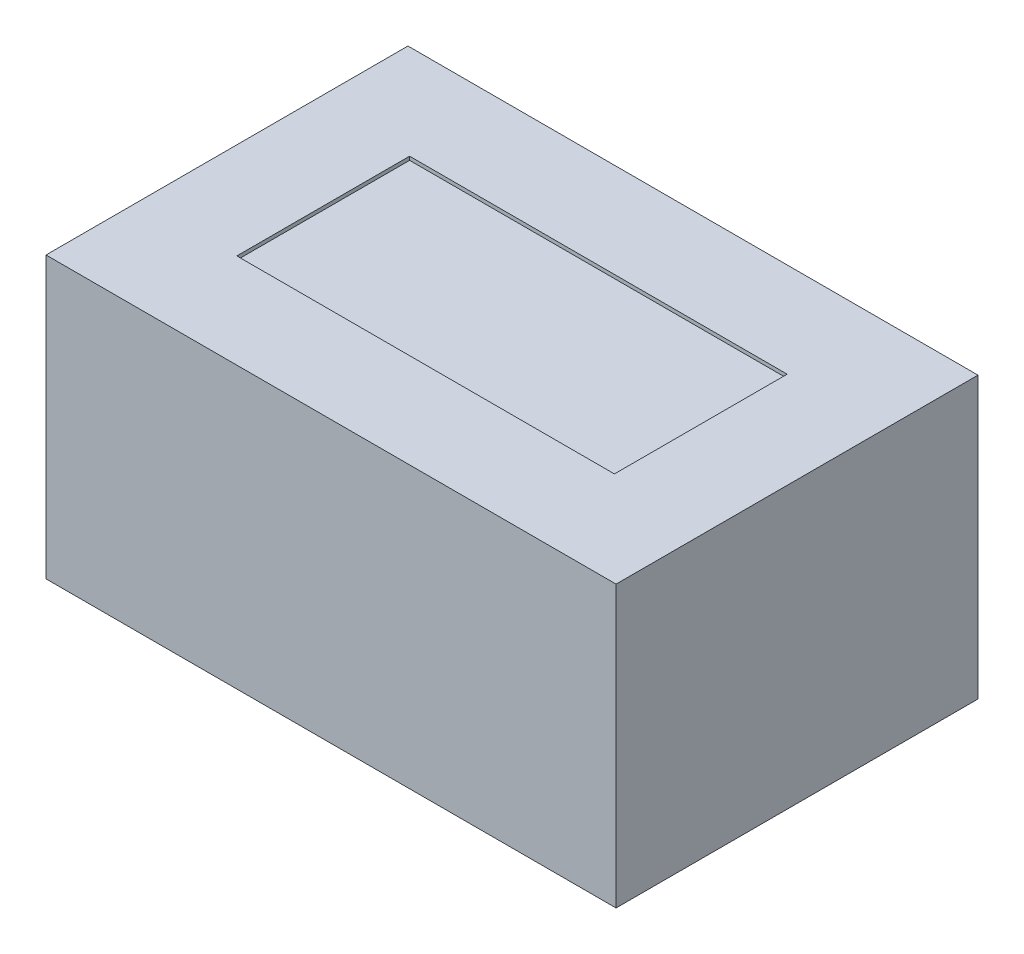
from build123d import *

# Parameters (mm, degrees)
CROQUIS1_W              = 315
CROQUIS1_H              = 200
SALIENTE_EXTRUIR1_DEPTH = 155
CROQUIS2_W              = 208.648711884
CROQUIS2_H              = 95.466627608
CORTAR_EXTRUIR1_DEPTH   = 2


with BuildPart() as part:
    # Croquis1 → Saliente-Extruir1 (new body)
    with BuildSketch(Plane(origin=(0, 0, 0), x_dir=(1, 0, 0), z_dir=(0, 1, 0))):
        Rectangle(CROQUIS1_W, CROQUIS1_H)
    extrude(amount=SALIENTE_EXTRUIR1_DEPTH)

    # Croquis2 → Cortar-Extruir1 (cut)
    with BuildSketch(Plane(origin=(0, 155, 0), x_dir=(1, 0, 0), z_dir=(0, 1, 0))):
        Rectangle(CROQUIS2_W, CROQUIS2_H)
    extrude(amount=-CORTAR_EXTRUIR1_DEPTH, mode=Mode.SUBTRACT)


solid = part.part
